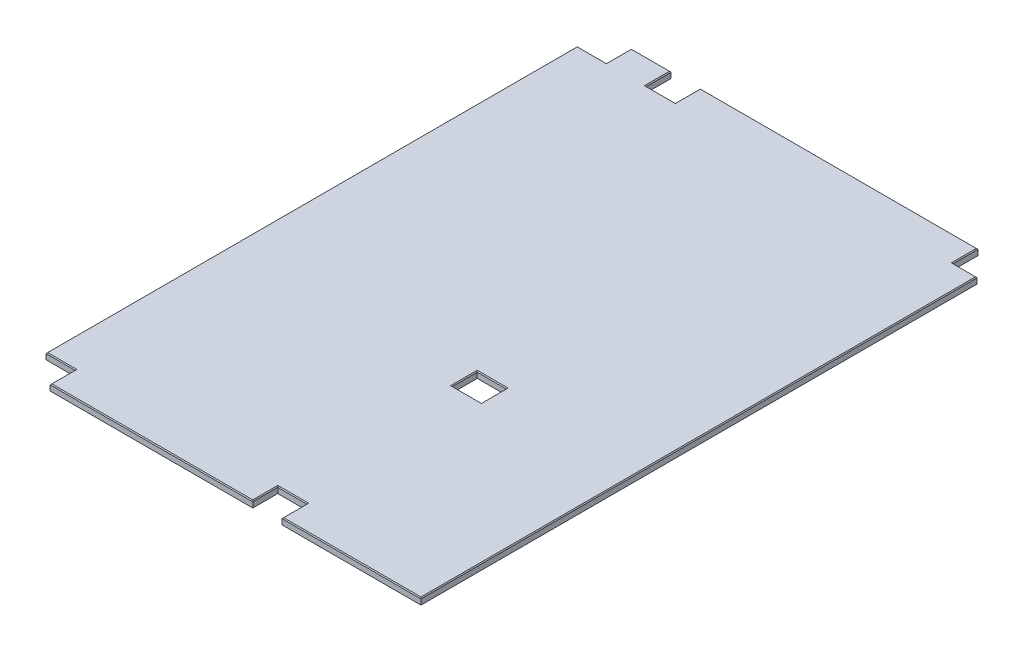
from build123d import *

# Parameters (mm, degrees)
SKETCH1_W           = 1219.2
SKETCH1_H           = 1771.65
BOSS_EXTRUDE1_DEPTH = 9.525
SKETCH3_W           = 88.9
SKETCH3_H           = 76.2
SKETCH3_W_2         = 73.6727
CUT_EXTRUDE2_DEPTH  = 20.05
CHAMFER1_SIZE       = 2.54


with BuildPart() as part:
    # Sketch1 → Boss-Extrude1 (new body, symmetric)
    with BuildSketch(Plane(origin=(0, 0, 0), x_dir=(1, 0, 0), z_dir=(0, 1, 0))):
        with Locations((609.6, 885.825)):
            Rectangle(SKETCH1_W, SKETCH1_H)
    extrude(amount=BOSS_EXTRUDE1_DEPTH, both=True)

    # Sketch3 → Cut-Extrude2 (cut, through all)
    with BuildSketch(Plane(origin=(0, 9.525, 0), x_dir=(1, 0, 0), z_dir=(0, 1, 0))):
        with Locations((44.45, 1733.55)):
            Rectangle(SKETCH3_W, SKETCH3_H)
        with Locations((254.6477, 1733.55)):
            Rectangle(SKETCH3_W, SKETCH3_H)
        with Locations((750.9256, 646.112499999)):
            Rectangle(SKETCH3_W, SKETCH3_H)
        with Locations((44.45, 38.1)):
            Rectangle(SKETCH3_W, SKETCH3_H)
        with Locations((750.9256, 38.1)):
            Rectangle(SKETCH3_W, SKETCH3_H)
        with Locations((1182.36365, 1733.55)):
            Rectangle(SKETCH3_W_2, SKETCH3_H)
    extrude(amount=-CUT_EXTRUDE2_DEPTH, mode=Mode.SUBTRACT)

    # Chamfer1
    chamfer1_edges = [part.edges().sort_by_distance(p)[0] for p in [
        (1219.2, 9.525, -847.725),
        (0, 9.525, -885.825),
        (397.6878, 9.525, 0),
        (1007.2878, 9.525, 0),
        (722.3125, 9.525, -1771.65),
        (149.54885, 9.525, -1771.65),
        (1145.5273, 9.525, -1733.55),
        (1182.36365, 9.525, -1695.45),
        (795.3756, 9.525, -38.1),
        (750.9256, 9.525, -76.2),
        (706.4756, 9.525, -38.1),
        (88.9, 9.525, -38.1),
        (44.45, 9.525, -76.2),
        (706.4756, 9.525, -646.112499999),
        (750.9256, 9.525, -608.012499999),
        (795.3756, 9.525, -646.112499999),
        (750.9256, 9.525, -684.212499999),
        (210.1977, 9.525, -1733.55),
        (254.6477, 9.525, -1695.45),
        (299.0977, 9.525, -1733.55),
        (44.45, 9.525, -1695.45),
        (88.9, 9.525, -1733.55),
    ]]
    chamfer(chamfer1_edges, length=CHAMFER1_SIZE)


solid = part.part
